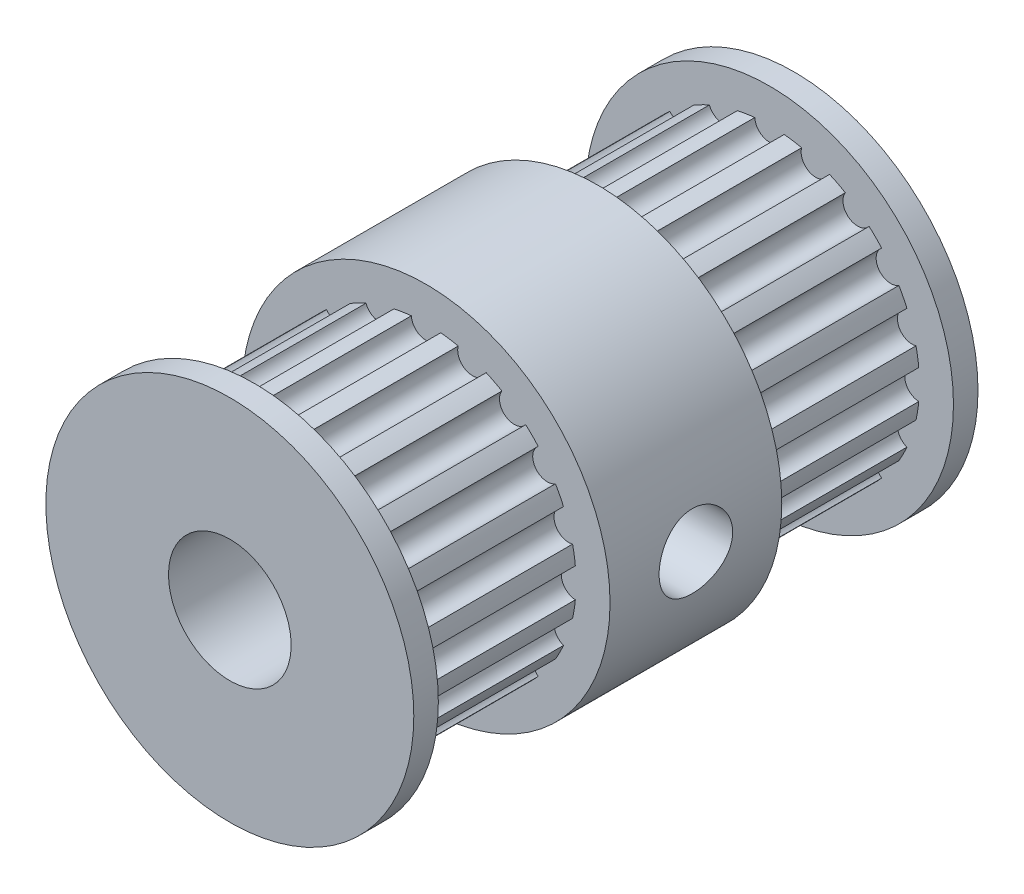
from build123d import *

# Parameters (mm, degrees)
SKETCH_1_R               = 7.5
EXTRUDE_1_DEPTH          = 3.5
SKETCH_2_R               = 6.115
EXTRUDE_2_DEPTH          = 7
CUT_EXTRUDE_START        = -7
CUT_EXTRUDE_3_DEPTH      = 7
SKETCH_3_R               = 7.5
EXTRUDE_3_DEPTH          = 1
SKETCH_5_R               = 1.5
CUT_EXTRUDE_1_DEPTH      = 7.5
PATTERN_CIRCULAR_1_COUNT = 2
PATTERN_CIRCULAR_1_ANGLE = 90
PATTERN_CIRCULAR_2_COUNT = 20
MIRROR_START             = -7
MIRROR_7_COPY_1_DEPTH    = 7
MIRROR_7_COPY_2_DEPTH    = 7
MIRROR_7_COPY_3_DEPTH    = 7
MIRROR_7_COPY_4_DEPTH    = 7
MIRROR_7_COPY_5_DEPTH    = 7
MIRROR_7_COPY_6_DEPTH    = 7
MIRROR_7_COPY_7_DEPTH    = 7
MIRROR_7_COPY_8_DEPTH    = 7
MIRROR_7_COPY_9_DEPTH    = 7
MIRROR_7_COPY_10_DEPTH   = 7
MIRROR_7_COPY_11_DEPTH   = 7
MIRROR_7_COPY_12_DEPTH   = 7
MIRROR_7_COPY_13_DEPTH   = 7
MIRROR_7_COPY_14_DEPTH   = 7
MIRROR_7_COPY_15_DEPTH   = 7
MIRROR_7_COPY_16_DEPTH   = 7
MIRROR_7_COPY_17_DEPTH   = 7
MIRROR_7_COPY_18_DEPTH   = 7
MIRROR_7_COPY_19_DEPTH   = 7
SKETCH_6_R               = 2.5
CUT_EXTRUDE_2_DEPTH      = 9
CUT_EXTRUDE_2_DEPTH_BACK = 16


with BuildPart() as part:
    # 草圖1 → 填料-伸長1 (new body, symmetric)
    with BuildSketch(Plane.XY):
        Circle(SKETCH_1_R)
    extrude(amount=EXTRUDE_1_DEPTH, both=True)

    # 草圖2 → 填料-伸長2 (add)
    with BuildSketch(Plane.XY.offset(3.5)):
        Circle(SKETCH_2_R)
    extrude_2 = extrude(amount=EXTRUDE_2_DEPTH)

    # 草圖7 → 除料-伸長3 (cut)
    with BuildSketch(Plane.XY.offset(10.5).offset(CUT_EXTRUDE_START)):
        with BuildLine():
            ThreePointArc((-0.599277509, 6.085564186), (0, 5.515), (0.599277509, 6.085564186))
            ThreePointArc((0.599277509, 6.085564186), (0, 6.115), (-0.599277509, 6.085564186))
        make_face()
    cut_extrude_3 = extrude(amount=CUT_EXTRUDE_3_DEPTH, mode=Mode.SUBTRACT)

    # 草圖3 → 填料-伸長3 (add)
    with BuildSketch(Plane.XY.offset(10.5)):
        Circle(SKETCH_3_R)
    extrude_3 = extrude(amount=EXTRUDE_3_DEPTH)

    # 草圖5 → 除料-伸長1 (cut)
    with BuildSketch(Plane(origin=(0, 0, 0), x_dir=(1, 0, 0), z_dir=(0, 1, 0))):
        Circle(SKETCH_5_R)
    cut_extrude_1 = extrude(amount=-CUT_EXTRUDE_1_DEPTH, mode=Mode.SUBTRACT)

    # 環狀複製排列1: 除料-伸長1 ×2 about axis
    pattern_circular_1_axis = Axis((0, 0, 3.5), (0, 0, 1))
    for i in range(1, PATTERN_CIRCULAR_1_COUNT):
        add(cut_extrude_1.rotate(pattern_circular_1_axis, i * PATTERN_CIRCULAR_1_ANGLE / (PATTERN_CIRCULAR_1_COUNT - 1)), mode=Mode.SUBTRACT)

    # 環狀複製排列2: 除料-伸長3 ×20 about axis
    pattern_circular_2_axis = Axis((0, 0, 0), (0, 0, 1))
    for i in range(1, PATTERN_CIRCULAR_2_COUNT):
        add(cut_extrude_3.rotate(pattern_circular_2_axis, i * 360 / PATTERN_CIRCULAR_2_COUNT), mode=Mode.SUBTRACT)

    # 鏡射7: 填料-伸長2, 填料-伸長3, 除料-伸長3 across plane
    add(extrude_2.mirror(Plane.XY))
    add(extrude_3.mirror(Plane.XY))
    add(cut_extrude_3.mirror(Plane.XY), mode=Mode.SUBTRACT)

    # 鏡射7 copy 1 sketch → 鏡射7 copy 1 (cut)
    with BuildSketch(Plane(origin=(0, 0, -10.5), x_dir=(0.951056516, 0.309016994, 0), z_dir=(0, 0, -1)).offset(MIRROR_START)):
        with BuildLine():
            ThreePointArc((-0.599277509, -6.085564186), (0, -5.515), (0.599277509, -6.085564186))
            ThreePointArc((0.599277509, -6.085564186), (0, -6.115), (-0.599277509, -6.085564186))
        make_face()
    extrude(amount=MIRROR_7_COPY_1_DEPTH, mode=Mode.SUBTRACT)

    # 鏡射7 copy 2 sketch → 鏡射7 copy 2 (cut)
    with BuildSketch(Plane(origin=(0, 0, -10.5), x_dir=(0.809016994, 0.587785252, 0), z_dir=(0, 0, -1)).offset(MIRROR_START)):
        with BuildLine():
            ThreePointArc((-0.599277509, -6.085564186), (0, -5.515), (0.599277509, -6.085564186))
            ThreePointArc((0.599277509, -6.085564186), (0, -6.115), (-0.599277509, -6.085564186))
        make_face()
    extrude(amount=MIRROR_7_COPY_2_DEPTH, mode=Mode.SUBTRACT)

    # 鏡射7 copy 3 sketch → 鏡射7 copy 3 (cut)
    with BuildSketch(Plane(origin=(0, 0, -10.5), x_dir=(0.587785252, 0.809016994, 0), z_dir=(0, 0, -1)).offset(MIRROR_START)):
        with BuildLine():
            ThreePointArc((-0.599277509, -6.085564186), (0, -5.515), (0.599277509, -6.085564186))
            ThreePointArc((0.599277509, -6.085564186), (0, -6.115), (-0.599277509, -6.085564186))
        make_face()
    extrude(amount=MIRROR_7_COPY_3_DEPTH, mode=Mode.SUBTRACT)

    # 鏡射7 copy 4 sketch → 鏡射7 copy 4 (cut)
    with BuildSketch(Plane(origin=(0, 0, -10.5), x_dir=(0.309016994, 0.951056516, 0), z_dir=(0, 0, -1)).offset(MIRROR_START)):
        with BuildLine():
            ThreePointArc((-0.599277509, -6.085564186), (0, -5.515), (0.599277509, -6.085564186))
            ThreePointArc((0.599277509, -6.085564186), (0, -6.115), (-0.599277509, -6.085564186))
        make_face()
    extrude(amount=MIRROR_7_COPY_4_DEPTH, mode=Mode.SUBTRACT)

    # 鏡射7 copy 5 sketch → 鏡射7 copy 5 (cut)
    with BuildSketch(Plane.YX.offset(10.5).offset(MIRROR_START)):
        with BuildLine():
            ThreePointArc((-0.599277509, -6.085564186), (0, -5.515), (0.599277509, -6.085564186))
            ThreePointArc((0.599277509, -6.085564186), (0, -6.115), (-0.599277509, -6.085564186))
        make_face()
    extrude(amount=MIRROR_7_COPY_5_DEPTH, mode=Mode.SUBTRACT)

    # 鏡射7 copy 6 sketch → 鏡射7 copy 6 (cut)
    with BuildSketch(Plane(origin=(0, 0, -10.5), x_dir=(-0.309016994, 0.951056516, 0), z_dir=(0, 0, -1)).offset(MIRROR_START)):
        with BuildLine():
            ThreePointArc((-0.599277509, -6.085564186), (0, -5.515), (0.599277509, -6.085564186))
            ThreePointArc((0.599277509, -6.085564186), (0, -6.115), (-0.599277509, -6.085564186))
        make_face()
    extrude(amount=MIRROR_7_COPY_6_DEPTH, mode=Mode.SUBTRACT)

    # 鏡射7 copy 7 sketch → 鏡射7 copy 7 (cut)
    with BuildSketch(Plane(origin=(0, 0, -10.5), x_dir=(-0.587785252, 0.809016994, 0), z_dir=(0, 0, -1)).offset(MIRROR_START)):
        with BuildLine():
            ThreePointArc((-0.599277509, -6.085564186), (0, -5.515), (0.599277509, -6.085564186))
            ThreePointArc((0.599277509, -6.085564186), (0, -6.115), (-0.599277509, -6.085564186))
        make_face()
    extrude(amount=MIRROR_7_COPY_7_DEPTH, mode=Mode.SUBTRACT)

    # 鏡射7 copy 8 sketch → 鏡射7 copy 8 (cut)
    with BuildSketch(Plane(origin=(0, 0, -10.5), x_dir=(-0.809016994, 0.587785252, 0), z_dir=(0, 0, -1)).offset(MIRROR_START)):
        with BuildLine():
            ThreePointArc((-0.599277509, -6.085564186), (0, -5.515), (0.599277509, -6.085564186))
            ThreePointArc((0.599277509, -6.085564186), (0, -6.115), (-0.599277509, -6.085564186))
        make_face()
    extrude(amount=MIRROR_7_COPY_8_DEPTH, mode=Mode.SUBTRACT)

    # 鏡射7 copy 9 sketch → 鏡射7 copy 9 (cut)
    with BuildSketch(Plane(origin=(0, 0, -10.5), x_dir=(-0.951056516, 0.309016994, 0), z_dir=(0, 0, -1)).offset(MIRROR_START)):
        with BuildLine():
            ThreePointArc((-0.599277509, -6.085564186), (0, -5.515), (0.599277509, -6.085564186))
            ThreePointArc((0.599277509, -6.085564186), (0, -6.115), (-0.599277509, -6.085564186))
        make_face()
    extrude(amount=MIRROR_7_COPY_9_DEPTH, mode=Mode.SUBTRACT)

    # 鏡射7 copy 10 sketch → 鏡射7 copy 10 (cut)
    with BuildSketch(Plane(origin=(0, 0, -10.5), x_dir=(-1, 0, 0), z_dir=(0, 0, -1)).offset(MIRROR_START)):
        with BuildLine():
            ThreePointArc((-0.599277509, -6.085564186), (0, -5.515), (0.599277509, -6.085564186))
            ThreePointArc((0.599277509, -6.085564186), (0, -6.115), (-0.599277509, -6.085564186))
        make_face()
    extrude(amount=MIRROR_7_COPY_10_DEPTH, mode=Mode.SUBTRACT)

    # 鏡射7 copy 11 sketch → 鏡射7 copy 11 (cut)
    with BuildSketch(Plane(origin=(0, 0, -10.5), x_dir=(-0.951056516, -0.309016994, 0), z_dir=(0, 0, -1)).offset(MIRROR_START)):
        with BuildLine():
            ThreePointArc((-0.599277509, -6.085564186), (0, -5.515), (0.599277509, -6.085564186))
            ThreePointArc((0.599277509, -6.085564186), (0, -6.115), (-0.599277509, -6.085564186))
        make_face()
    extrude(amount=MIRROR_7_COPY_11_DEPTH, mode=Mode.SUBTRACT)

    # 鏡射7 copy 12 sketch → 鏡射7 copy 12 (cut)
    with BuildSketch(Plane(origin=(0, 0, -10.5), x_dir=(-0.809016994, -0.587785252, 0), z_dir=(0, 0, -1)).offset(MIRROR_START)):
        with BuildLine():
            ThreePointArc((-0.599277509, -6.085564186), (0, -5.515), (0.599277509, -6.085564186))
            ThreePointArc((0.599277509, -6.085564186), (0, -6.115), (-0.599277509, -6.085564186))
        make_face()
    extrude(amount=MIRROR_7_COPY_12_DEPTH, mode=Mode.SUBTRACT)

    # 鏡射7 copy 13 sketch → 鏡射7 copy 13 (cut)
    with BuildSketch(Plane(origin=(0, 0, -10.5), x_dir=(-0.587785252, -0.809016994, 0), z_dir=(0, 0, -1)).offset(MIRROR_START)):
        with BuildLine():
            ThreePointArc((-0.599277509, -6.085564186), (0, -5.515), (0.599277509, -6.085564186))
            ThreePointArc((0.599277509, -6.085564186), (0, -6.115), (-0.599277509, -6.085564186))
        make_face()
    extrude(amount=MIRROR_7_COPY_13_DEPTH, mode=Mode.SUBTRACT)

    # 鏡射7 copy 14 sketch → 鏡射7 copy 14 (cut)
    with BuildSketch(Plane(origin=(0, 0, -10.5), x_dir=(-0.309016994, -0.951056516, 0), z_dir=(0, 0, -1)).offset(MIRROR_START)):
        with BuildLine():
            ThreePointArc((-0.599277509, -6.085564186), (0, -5.515), (0.599277509, -6.085564186))
            ThreePointArc((0.599277509, -6.085564186), (0, -6.115), (-0.599277509, -6.085564186))
        make_face()
    extrude(amount=MIRROR_7_COPY_14_DEPTH, mode=Mode.SUBTRACT)

    # 鏡射7 copy 15 sketch → 鏡射7 copy 15 (cut)
    with BuildSketch(Plane(origin=(0, 0, -10.5), x_dir=(0, -1, 0), z_dir=(0, 0, -1)).offset(MIRROR_START)):
        with BuildLine():
            ThreePointArc((-0.599277509, -6.085564186), (0, -5.515), (0.599277509, -6.085564186))
            ThreePointArc((0.599277509, -6.085564186), (0, -6.115), (-0.599277509, -6.085564186))
        make_face()
    extrude(amount=MIRROR_7_COPY_15_DEPTH, mode=Mode.SUBTRACT)

    # 鏡射7 copy 16 sketch → 鏡射7 copy 16 (cut)
    with BuildSketch(Plane(origin=(0, 0, -10.5), x_dir=(0.309016994, -0.951056516, 0), z_dir=(0, 0, -1)).offset(MIRROR_START)):
        with BuildLine():
            ThreePointArc((-0.599277509, -6.085564186), (0, -5.515), (0.599277509, -6.085564186))
            ThreePointArc((0.599277509, -6.085564186), (0, -6.115), (-0.599277509, -6.085564186))
        make_face()
    extrude(amount=MIRROR_7_COPY_16_DEPTH, mode=Mode.SUBTRACT)

    # 鏡射7 copy 17 sketch → 鏡射7 copy 17 (cut)
    with BuildSketch(Plane(origin=(0, 0, -10.5), x_dir=(0.587785252, -0.809016994, 0), z_dir=(0, 0, -1)).offset(MIRROR_START)):
        with BuildLine():
            ThreePointArc((-0.599277509, -6.085564186), (0, -5.515), (0.599277509, -6.085564186))
            ThreePointArc((0.599277509, -6.085564186), (0, -6.115), (-0.599277509, -6.085564186))
        make_face()
    extrude(amount=MIRROR_7_COPY_17_DEPTH, mode=Mode.SUBTRACT)

    # 鏡射7 copy 18 sketch → 鏡射7 copy 18 (cut)
    with BuildSketch(Plane(origin=(0, 0, -10.5), x_dir=(0.809016994, -0.587785252, 0), z_dir=(0, 0, -1)).offset(MIRROR_START)):
        with BuildLine():
            ThreePointArc((-0.599277509, -6.085564186), (0, -5.515), (0.599277509, -6.085564186))
            ThreePointArc((0.599277509, -6.085564186), (0, -6.115), (-0.599277509, -6.085564186))
        make_face()
    extrude(amount=MIRROR_7_COPY_18_DEPTH, mode=Mode.SUBTRACT)

    # 鏡射7 copy 19 sketch → 鏡射7 copy 19 (cut)
    with BuildSketch(Plane(origin=(0, 0, -10.5), x_dir=(0.951056516, -0.309016994, 0), z_dir=(0, 0, -1)).offset(MIRROR_START)):
        with BuildLine():
            ThreePointArc((-0.599277509, -6.085564186), (0, -5.515), (0.599277509, -6.085564186))
            ThreePointArc((0.599277509, -6.085564186), (0, -6.115), (-0.599277509, -6.085564186))
        make_face()
    extrude(amount=MIRROR_7_COPY_19_DEPTH, mode=Mode.SUBTRACT)

    # 草圖6 → 除料-伸長2 (cut, two sides)
    with BuildSketch(Plane(origin=(0, 0, -3.5), x_dir=(-1, 0, 0), z_dir=(0, 0, -1))) as cut_extrude_2_sk:
        Circle(SKETCH_6_R)
    extrude(amount=CUT_EXTRUDE_2_DEPTH, mode=Mode.SUBTRACT)
    extrude(cut_extrude_2_sk.sketch, amount=-CUT_EXTRUDE_2_DEPTH_BACK, mode=Mode.SUBTRACT)


solid = part.part
